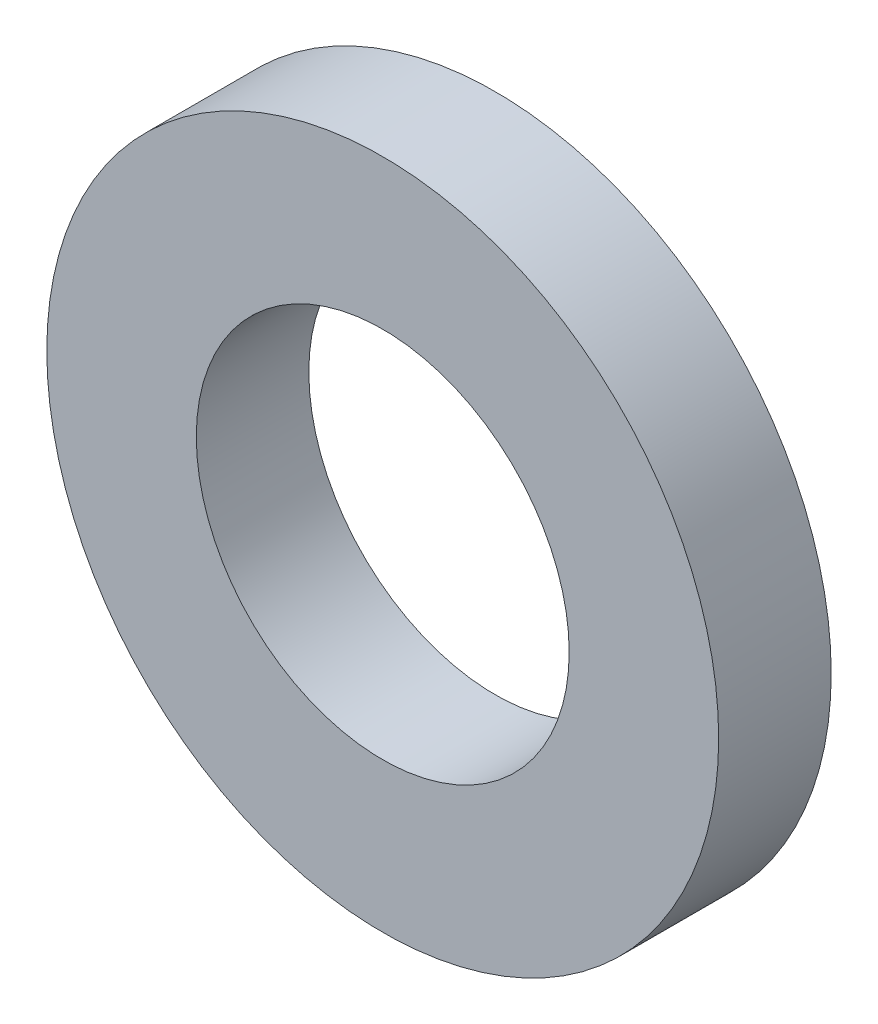
from build123d import *

# Parameters (mm, degrees)
SKETCH1_R      = 2.6543
SKETCH1_R_2    = 1.4732
EXTRUDE1_DEPTH = 0.889


with BuildPart() as part:
    # Sketch1 → Extrude1 (new body)
    with BuildSketch(Plane.XY):
        Circle(SKETCH1_R)
        Circle(SKETCH1_R_2, mode=Mode.SUBTRACT)
    extrude(amount=EXTRUDE1_DEPTH)


solid = part.part
